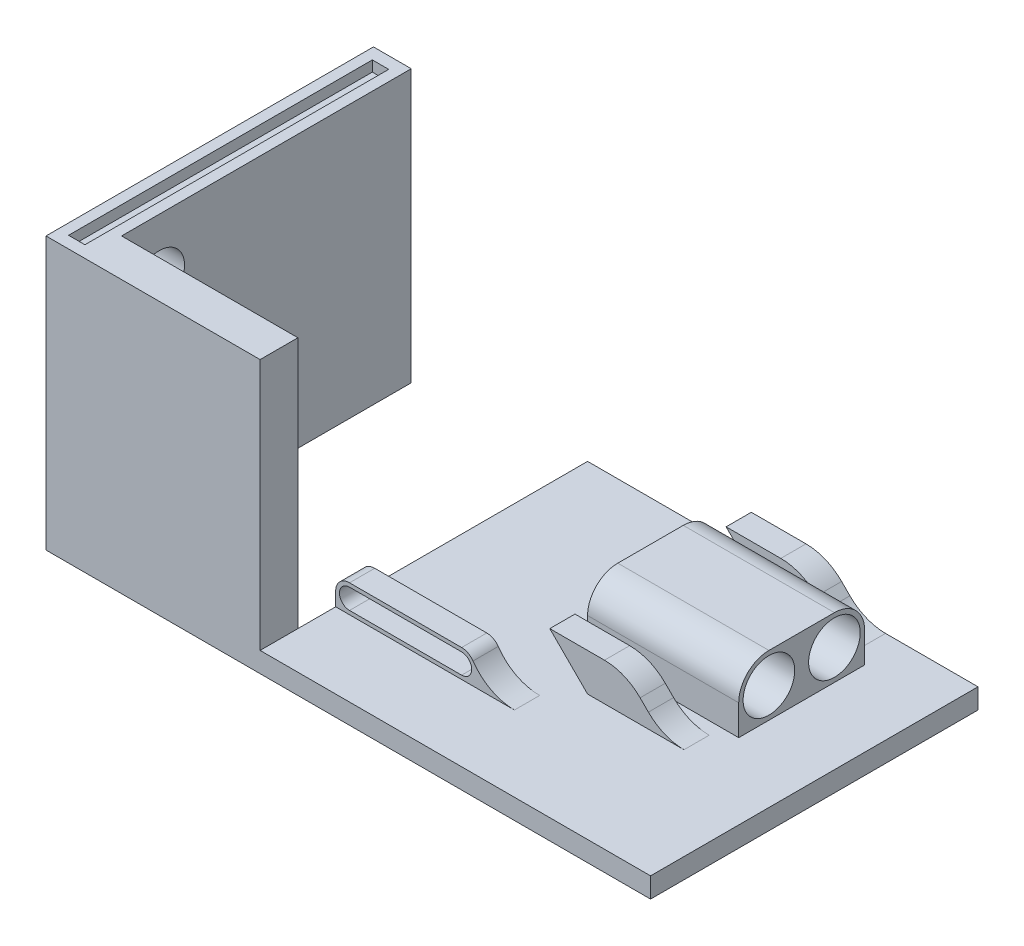
from build123d import *

# Parameters (mm, degrees)
SKETCH1_W                       = 165
SKETCH1_H                       = 65
BOSS_EXTRUDE1_DEPTH             = 4
BOSS_EXTRUDE2_REACH             = 90.761
BOSS_EXTRUDE2_DIRECTION_2_DEPTH = 50
BOSS_EXTRUDE4_START             = -15
BOSS_EXTRUDE4_DEPTH             = 5
FILLET1_R                       = 10
BOSS_EXTRUDE5_DEPTH             = 5
FILLET3_R                       = 10
LPATTERN1_COUNT                 = 2
LPATTERN1_PITCH                 = 35
FILLET3_OF_LPATTERN1_R          = 10
SKETCH5_W                       = 82.5
SKETCH5_H                       = 65
CUT_EXTRUDE1_DEPTH              = 5
BOSS_EXTRUDE6_START             = -20
SKETCH6_R                       = 5.125000000000001
SKETCH6_R_2                     = 5.125
BOSS_EXTRUDE6_DEPTH             = 30
CUT_EXTRUDE6_DEPTH              = 2.1
SKETCH8_R                       = 4.999999999999999
CUT_EXTRUDE3_DEPTH              = 7.5
SKETCH19_W                      = 5
SKETCH19_H                      = 65
CUT_EXTRUDE11_DEPTH             = 10


with BuildPart() as part:
    # Sketch1 → Boss-Extrude1 (new body)
    with BuildSketch(Plane(origin=(0, 0, 0), x_dir=(1, 0, 0), z_dir=(0, 1, 0))):
        Rectangle(SKETCH1_W, SKETCH1_H)
    extrude(amount=BOSS_EXTRUDE1_DEPTH)

    # Boss-Extrude2: up to this face of the body (flat: up to its plane)
    boss_extrude2_end = Plane(part.part.faces().sort_by_distance((0, 0, 0))[0])
    # Sketch2 → Boss-Extrude2 (add, up to the picked face)
    with BuildSketch(Plane(origin=(0, 4, 0), x_dir=(1, 0, 0), z_dir=(0, 1, 0)), mode=Mode.PRIVATE) as boss_extrude2_sk1:
        Polygon((-82.5, -32.5), (-124.99999999999999, -32.50000000000001), (-124.99999999999999, 32.5), (-117.50000000000001, 32.5), (-117.50000000000001, -25), (-82.5, -25), align=None)
    boss_extrude2_tool1 = split(extrude(boss_extrude2_sk1.sketch, amount=-BOSS_EXTRUDE2_REACH, mode=Mode.PRIVATE), bisect_by=boss_extrude2_end, keep=Keep.BOTH, mode=Mode.PRIVATE)
    add(boss_extrude2_tool1.solids().sort_by(Axis((-103.75, 4, 31.723389), (0, -1, 0)))[0])

    # Sketch2 → Boss-Extrude2 direction 2 (add)
    with BuildSketch(Plane(origin=(0, 4, 0), x_dir=(1, 0, 0), z_dir=(0, 1, 0))):
        Polygon((-82.5, -32.5), (-124.99999999999999, -32.50000000000001), (-124.99999999999999, 32.5), (-117.50000000000001, 32.5), (-117.50000000000001, -25), (-82.5, -25), align=None)
    extrude(amount=BOSS_EXTRUDE2_DIRECTION_2_DEPTH)

    # Sketch3 → Boss-Extrude4 (add)
    with BuildSketch(Plane.XY.offset(32.5).offset(BOSS_EXTRUDE4_START)):
        with BuildLine():
            Line((-79.75, 9.500000000000004), (-57.50000000000001, 9.500000000000005))
            ThreePointArc((-57.50000000000001, 9.500000000000005), (-54.75000000000001, 6.75), (-57.50000000000001, 4))
            Line((-57.50000000000001, 4), (-82.5, 4))
            Line((-82.5, 4), (-82.5, 6.75))
            ThreePointArc((-82.5, 6.75), (-81.69454364826301, 8.694543648263005), (-79.75, 9.500000000000004))
        make_face()
        with BuildLine():
            Line((-79.75, 8.749999999999996), (-57.50000000000001, 8.75))
            ThreePointArc((-57.50000000000001, 8.75), (-55.50000000000001, 6.75), (-57.50000000000001, 4.749999999999999))
            Line((-57.50000000000001, 4.749999999999999), (-79.75, 4.750000000000004))
            ThreePointArc((-79.75, 4.750000000000004), (-81.75, 6.749999999999998), (-79.75, 8.749999999999996))
        make_face(mode=Mode.SUBTRACT)
    extrude(amount=-BOSS_EXTRUDE4_DEPTH)

    # Fillet1
    fillet1_edges = [part.edges().sort_by_distance(p)[0] for p in [
        (-57.50000000000001, 4.000000000000001, 15),
    ]]
    fillet(fillet1_edges, radius=FILLET1_R)

    # Sketch4 → Boss-Extrude5 (add)
    with BuildSketch(Plane(origin=(0, 0, -32.5), x_dir=(-1, 0, 0), z_dir=(0, 0, -1))):
        Polygon((27.500000000000004, 4), (35.00000000000008, 11.5), (50.00000000000008, 11.5), (42.5, 4), align=None)
    boss_extrude5 = extrude(amount=-BOSS_EXTRUDE5_DEPTH)

    # Fillet3
    fillet3_edges = [part.edges().sort_by_distance(p)[0] for p in [
        (-27.500000000000004, 4, -30),
        (-35.00000000000008, 11.5, -30),
    ]]
    fillet(fillet3_edges, radius=FILLET3_R)

    # LPattern1: Boss-Extrude5 ×2
    with Locations(*[(0, 0, i * LPATTERN1_PITCH) for i in range(1, LPATTERN1_COUNT)]):
        add(boss_extrude5)

    # Fillet3 of LPattern1
    fillet3_of_lpattern1_edges = [part.edges().sort_by_distance(p)[0] for p in [
        (-27.500000000000004, 4, 5),
        (-35.00000000000008, 11.5, 5),
    ]]
    fillet(fillet3_of_lpattern1_edges, radius=FILLET3_OF_LPATTERN1_R)

    # Sketch5 → Cut-Extrude1 (cut)
    with BuildSketch(Plane(origin=(0, 4, 0), x_dir=(1, 0, 0), z_dir=(0, 1, 0))):
        with Locations((41.25, 0)):
            Rectangle(SKETCH5_W, SKETCH5_H)
    extrude(amount=-CUT_EXTRUDE1_DEPTH, mode=Mode.SUBTRACT)

    # Sketch6 → Boss-Extrude6 (add)
    with BuildSketch(Plane(origin=(0, 0, 0), x_dir=(0, 0, -1), z_dir=(1, 0, 0)).offset(BOSS_EXTRUDE6_START)):
        with BuildLine():
            Line((1.1e-16, 10), (1.1e-16, 4))
            Line((1.1e-16, 4), (25, 4.0000000000000036))
            Line((25, 4.0000000000000036), (25, 10.000000000000002))
            ThreePointArc((25, 10.000000000000002), (23.242640687119287, 14.242640687119286), (19.000000000000004, 16))
            Line((19.000000000000004, 16), (6, 16))
            ThreePointArc((6, 16), (1.7573593128807152, 14.242640687119286), (1.1e-16, 10))
        make_face()
        with Locations((6.000000000000001, 10)):
            Circle(SKETCH6_R, mode=Mode.SUBTRACT)
        with Locations((19.000000000000004, 10.000000000000002)):
            Circle(SKETCH6_R_2, mode=Mode.SUBTRACT)
    extrude(amount=-BOSS_EXTRUDE6_DEPTH)

    # Sketch13 → Cut-Extrude6 (cut)
    with BuildSketch(Plane(origin=(0, 54.00000000000001, 0), x_dir=(1, 0, 0), z_dir=(0, 1, 0))):
        Polygon((-119.625, 30.15), (-122.875, 30.15), (-122.87499999999999, -30.150000000000006), (-119.625, -30.150000000000006), align=None)
    extrude(amount=-CUT_EXTRUDE6_DEPTH, mode=Mode.SUBTRACT)

    # Sketch8 → Cut-Extrude3 (cut)
    with BuildSketch(Plane.ZY.offset(124.99999999999999)):
        with Locations((17.50000000000002, 42.74019942711779)):
            Circle(SKETCH8_R)
    extrude(amount=-CUT_EXTRUDE3_DEPTH, mode=Mode.SUBTRACT)

    # Sketch19 → Cut-Extrude11 (cut)
    with BuildSketch(Plane(origin=(0, 4, 0), x_dir=(1, 0, 0), z_dir=(0, 1, 0))):
        with Locations((-2.5, 0)):
            Rectangle(SKETCH19_W, SKETCH19_H)
    extrude(amount=-CUT_EXTRUDE11_DEPTH, mode=Mode.SUBTRACT)


solid = part.part
